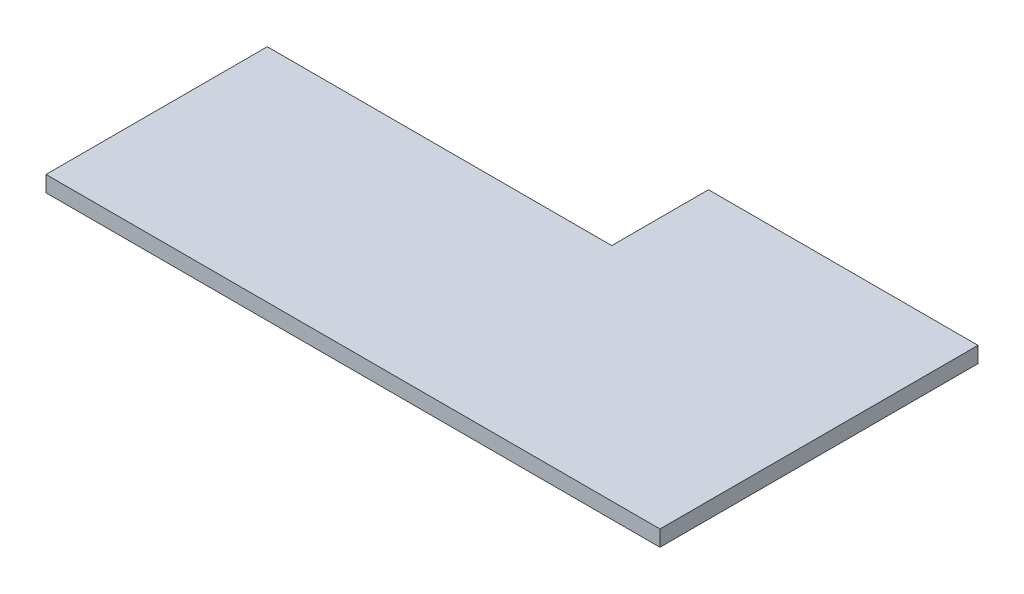
from build123d import *

# Parameters (mm, degrees)
BOSS_EXTRUDE2_DEPTH = 2.95


with BuildPart() as part:
    # Sketch1 → Boss-Extrude2 (new body)
    with BuildSketch(Plane(origin=(0, 0, 0), x_dir=(1, 0, 0), z_dir=(0, 1, 0))):
        Polygon((-63.91, 13.622104667), (-63.91, -27.427895333), (50, -27.427895333), (50, 16.572104667), (50, 31.572104667), (0, 31.572104667), (0, 13.622104667), align=None)
    extrude(amount=BOSS_EXTRUDE2_DEPTH)


solid = part.part
